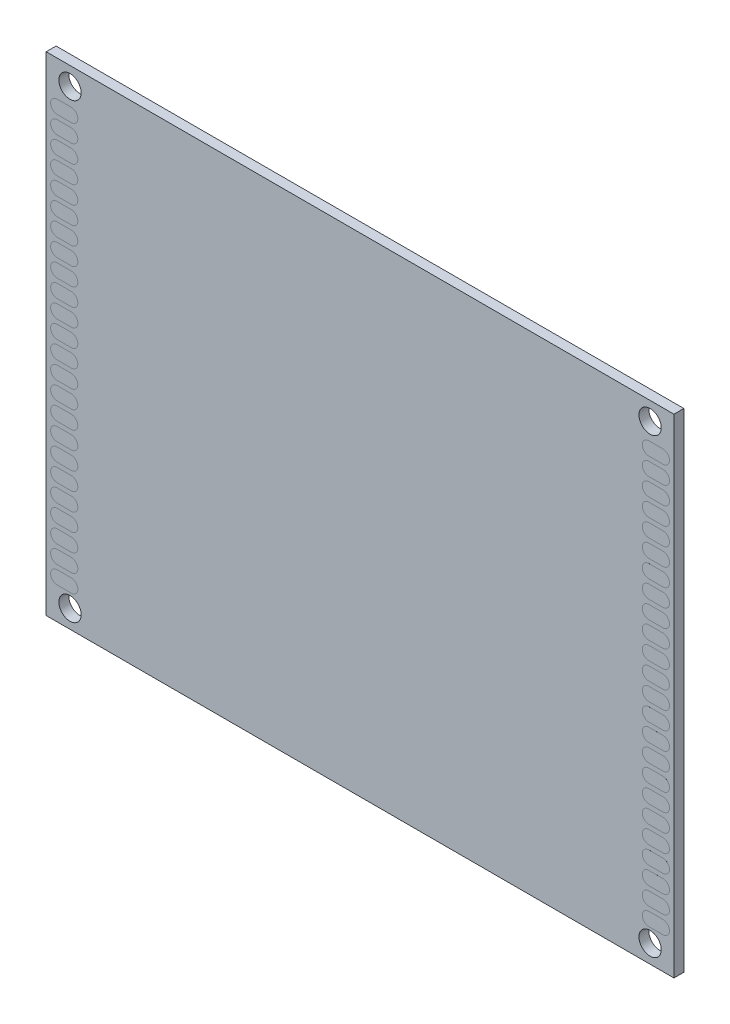
from build123d import *

# Parameters (mm, degrees)
SKETCH2_W               = 90
SKETCH2_H               = 70
BOSS_EXTRUDE1_DEPTH     = 0.71
SKETCH3_R               = 1.6
CUT_EXTRUDE1_DEPTH      = 1.71
CUT_EXTRUDE1_DEPTH_BACK = 1.71
BOSS_EXTRUDE2_START     = -0.711
BOSS_EXTRUDE2_DEPTH     = 1.4211


with BuildPart() as part:
    # Sketch2 → Boss-Extrude1 (new body, symmetric)
    with BuildSketch(Plane.XY):
        Rectangle(SKETCH2_W, SKETCH2_H)
    extrude(amount=BOSS_EXTRUDE1_DEPTH, both=True)

    # Sketch3 → Cut-Extrude1 (cut, two sides)
    with BuildSketch(Plane.XY) as cut_extrude1_sk:
        with Locations((-41.58, 32.4)):
            Circle(SKETCH3_R)
        with Locations((41.58, 32.4)):
            Circle(SKETCH3_R)
        with Locations((41.58, -32.4)):
            Circle(SKETCH3_R)
        with Locations((-41.58, -32.4)):
            Circle(SKETCH3_R)
    extrude(amount=CUT_EXTRUDE1_DEPTH, mode=Mode.SUBTRACT)
    extrude(cut_extrude1_sk.sketch, amount=-CUT_EXTRUDE1_DEPTH_BACK, mode=Mode.SUBTRACT)

    # Sketch4 → Boss-Extrude2 (add)
    with BuildSketch(Plane.XY.offset(BOSS_EXTRUDE2_START)):
        with BuildLine():
            Line((-43.41, 28), (-41.41, 28))
            ThreePointArc((-41.41, 28), (-40.46, 28.95), (-41.41, 29.9))
            Line((-41.41, 29.9), (-43.41, 29.9))
            ThreePointArc((-43.41, 29.9), (-44.36, 28.95), (-43.41, 28))
        make_face()
        with BuildLine():
            Line((-43.41, 25.46), (-41.41, 25.46))
            ThreePointArc((-41.41, 25.46), (-40.46, 26.41), (-41.41, 27.36))
            Line((-41.41, 27.36), (-43.41, 27.36))
            ThreePointArc((-43.41, 27.36), (-44.36, 26.41), (-43.41, 25.46))
        make_face()
        with BuildLine():
            Line((-43.41, 22.92), (-41.41, 22.92))
            ThreePointArc((-41.41, 22.92), (-40.46, 23.87), (-41.41, 24.82))
            Line((-41.41, 24.82), (-43.41, 24.82))
            ThreePointArc((-43.41, 24.82), (-44.36, 23.87), (-43.41, 22.92))
        make_face()
        with BuildLine():
            Line((-43.41, 20.38), (-41.41, 20.38))
            ThreePointArc((-41.41, 20.38), (-40.46, 21.33), (-41.41, 22.28))
            Line((-41.41, 22.28), (-43.41, 22.28))
            ThreePointArc((-43.41, 22.28), (-44.36, 21.33), (-43.41, 20.38))
        make_face()
        with BuildLine():
            Line((-43.41, 17.84), (-41.41, 17.84))
            ThreePointArc((-41.41, 17.84), (-40.46, 18.79), (-41.41, 19.74))
            Line((-41.41, 19.74), (-43.41, 19.74))
            ThreePointArc((-43.41, 19.74), (-44.36, 18.79), (-43.41, 17.84))
        make_face()
        with BuildLine():
            Line((-43.41, 15.3), (-41.41, 15.3))
            ThreePointArc((-41.41, 15.3), (-40.46, 16.25), (-41.41, 17.2))
            Line((-41.41, 17.2), (-43.41, 17.2))
            ThreePointArc((-43.41, 17.2), (-44.36, 16.25), (-43.41, 15.3))
        make_face()
        with BuildLine():
            Line((-43.41, 12.76), (-41.41, 12.76))
            ThreePointArc((-41.41, 12.76), (-40.46, 13.71), (-41.41, 14.66))
            Line((-41.41, 14.66), (-43.41, 14.66))
            ThreePointArc((-43.41, 14.66), (-44.36, 13.71), (-43.41, 12.76))
        make_face()
        with BuildLine():
            Line((-43.41, 10.22), (-41.41, 10.22))
            ThreePointArc((-41.41, 10.22), (-40.46, 11.17), (-41.41, 12.12))
            Line((-41.41, 12.12), (-43.41, 12.12))
            ThreePointArc((-43.41, 12.12), (-44.36, 11.17), (-43.41, 10.22))
        make_face()
        with BuildLine():
            Line((-43.41, 7.68), (-41.41, 7.68))
            ThreePointArc((-41.41, 7.68), (-40.46, 8.63), (-41.41, 9.58))
            Line((-41.41, 9.58), (-43.41, 9.58))
            ThreePointArc((-43.41, 9.58), (-44.36, 8.63), (-43.41, 7.68))
        make_face()
        with BuildLine():
            Line((-43.41, 5.14), (-41.41, 5.14))
            ThreePointArc((-41.41, 5.14), (-40.46, 6.09), (-41.41, 7.04))
            Line((-41.41, 7.04), (-43.41, 7.04))
            ThreePointArc((-43.41, 7.04), (-44.36, 6.09), (-43.41, 5.14))
        make_face()
        with BuildLine():
            Line((-43.41, 2.6), (-41.41, 2.6))
            ThreePointArc((-41.41, 2.6), (-40.46, 3.55), (-41.41, 4.5))
            Line((-41.41, 4.5), (-43.41, 4.5))
            ThreePointArc((-43.41, 4.5), (-44.36, 3.55), (-43.41, 2.6))
        make_face()
        with BuildLine():
            Line((-43.41, 0.06), (-41.41, 0.06))
            ThreePointArc((-41.41, 0.06), (-40.46, 1.01), (-41.41, 1.96))
            Line((-41.41, 1.96), (-43.41, 1.96))
            ThreePointArc((-43.41, 1.96), (-44.36, 1.01), (-43.41, 0.06))
        make_face()
        with BuildLine():
            Line((-43.41, -2.48), (-41.41, -2.48))
            ThreePointArc((-41.41, -2.48), (-40.46, -1.53), (-41.41, -0.58))
            Line((-41.41, -0.58), (-43.41, -0.58))
            ThreePointArc((-43.41, -0.58), (-44.36, -1.53), (-43.41, -2.48))
        make_face()
        with BuildLine():
            Line((-43.41, -5.02), (-41.41, -5.02))
            ThreePointArc((-41.41, -5.02), (-40.46, -4.07), (-41.41, -3.12))
            Line((-41.41, -3.12), (-43.41, -3.12))
            ThreePointArc((-43.41, -3.12), (-44.36, -4.07), (-43.41, -5.02))
        make_face()
        with BuildLine():
            Line((-43.41, -7.56), (-41.41, -7.56))
            ThreePointArc((-41.41, -7.56), (-40.46, -6.61), (-41.41, -5.66))
            Line((-41.41, -5.66), (-43.41, -5.66))
            ThreePointArc((-43.41, -5.66), (-44.36, -6.61), (-43.41, -7.56))
        make_face()
        with BuildLine():
            Line((-43.41, -10.1), (-41.41, -10.1))
            ThreePointArc((-41.41, -10.1), (-40.46, -9.15), (-41.41, -8.2))
            Line((-41.41, -8.2), (-43.41, -8.2))
            ThreePointArc((-43.41, -8.2), (-44.36, -9.15), (-43.41, -10.1))
        make_face()
        with BuildLine():
            Line((-43.41, -12.64), (-41.41, -12.64))
            ThreePointArc((-41.41, -12.64), (-40.46, -11.69), (-41.41, -10.74))
            Line((-41.41, -10.74), (-43.41, -10.74))
            ThreePointArc((-43.41, -10.74), (-44.36, -11.69), (-43.41, -12.64))
        make_face()
        with BuildLine():
            Line((-43.41, -15.18), (-41.41, -15.18))
            ThreePointArc((-41.41, -15.18), (-40.46, -14.23), (-41.41, -13.28))
            Line((-41.41, -13.28), (-43.41, -13.28))
            ThreePointArc((-43.41, -13.28), (-44.36, -14.23), (-43.41, -15.18))
        make_face()
        with BuildLine():
            Line((-43.41, -17.72), (-41.41, -17.72))
            ThreePointArc((-41.41, -17.72), (-40.46, -16.77), (-41.41, -15.82))
            Line((-41.41, -15.82), (-43.41, -15.82))
            ThreePointArc((-43.41, -15.82), (-44.36, -16.77), (-43.41, -17.72))
        make_face()
        with BuildLine():
            Line((-43.41, -20.26), (-41.41, -20.26))
            ThreePointArc((-41.41, -20.26), (-40.46, -19.31), (-41.41, -18.36))
            Line((-41.41, -18.36), (-43.41, -18.36))
            ThreePointArc((-43.41, -18.36), (-44.36, -19.31), (-43.41, -20.26))
        make_face()
        with BuildLine():
            Line((-43.41, -22.8), (-41.41, -22.8))
            ThreePointArc((-41.41, -22.8), (-40.46, -21.85), (-41.41, -20.9))
            Line((-41.41, -20.9), (-43.41, -20.9))
            ThreePointArc((-43.41, -20.9), (-44.36, -21.85), (-43.41, -22.8))
        make_face()
        with BuildLine():
            Line((-43.41, -25.34), (-41.41, -25.34))
            ThreePointArc((-41.41, -25.34), (-40.46, -24.39), (-41.41, -23.44))
            Line((-41.41, -23.44), (-43.41, -23.44))
            ThreePointArc((-43.41, -23.44), (-44.36, -24.39), (-43.41, -25.34))
        make_face()
        with BuildLine():
            Line((-43.41, -27.88), (-41.41, -27.88))
            ThreePointArc((-41.41, -27.88), (-40.46, -26.93), (-41.41, -25.98))
            Line((-41.41, -25.98), (-43.41, -25.98))
            ThreePointArc((-43.41, -25.98), (-44.36, -26.93), (-43.41, -27.88))
        make_face()
        with BuildLine():
            Line((-43.41, -30.42), (-41.41, -30.42))
            ThreePointArc((-41.41, -30.42), (-40.46, -29.47), (-41.41, -28.52))
            Line((-41.41, -28.52), (-43.41, -28.52))
            ThreePointArc((-43.41, -28.52), (-44.36, -29.47), (-43.41, -30.42))
        make_face()
    boss_extrude2 = extrude(amount=BOSS_EXTRUDE2_DEPTH)

    # Mirror1: Boss-Extrude2 across plane
    add(boss_extrude2.mirror(Plane(origin=(0, 0, 0), x_dir=(0, 0, 1), z_dir=(1, 0, 0))))


solid = part.part
